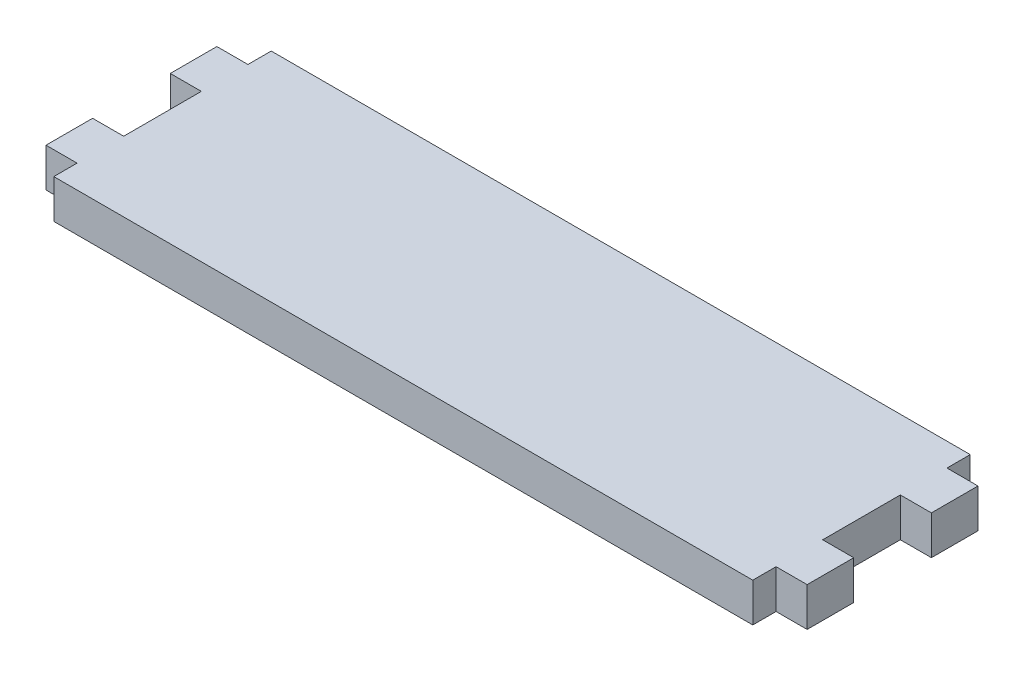
from build123d import *

# Parameters (mm, degrees)
BOSS_EXTRUDE1_DEPTH = 5


with BuildPart() as part:
    # Sketch1 → Boss-Extrude1 (new body)
    with BuildSketch(Plane(origin=(0, 0, 0), x_dir=(1, 0, 0), z_dir=(0, 1, 0))):
        Polygon((0, 0), (0, 3), (-4, 3), (-4, 9), (0, 9), (0, 19), (-4, 19), (-4, 25), (0, 25), (0, 28), (90, 28), (90, 25), (94, 25), (94, 19), (90, 19), (90, 9), (94, 9), (94, 3), (90, 3), (90, 0), align=None)
    extrude(amount=BOSS_EXTRUDE1_DEPTH)


solid = part.part
